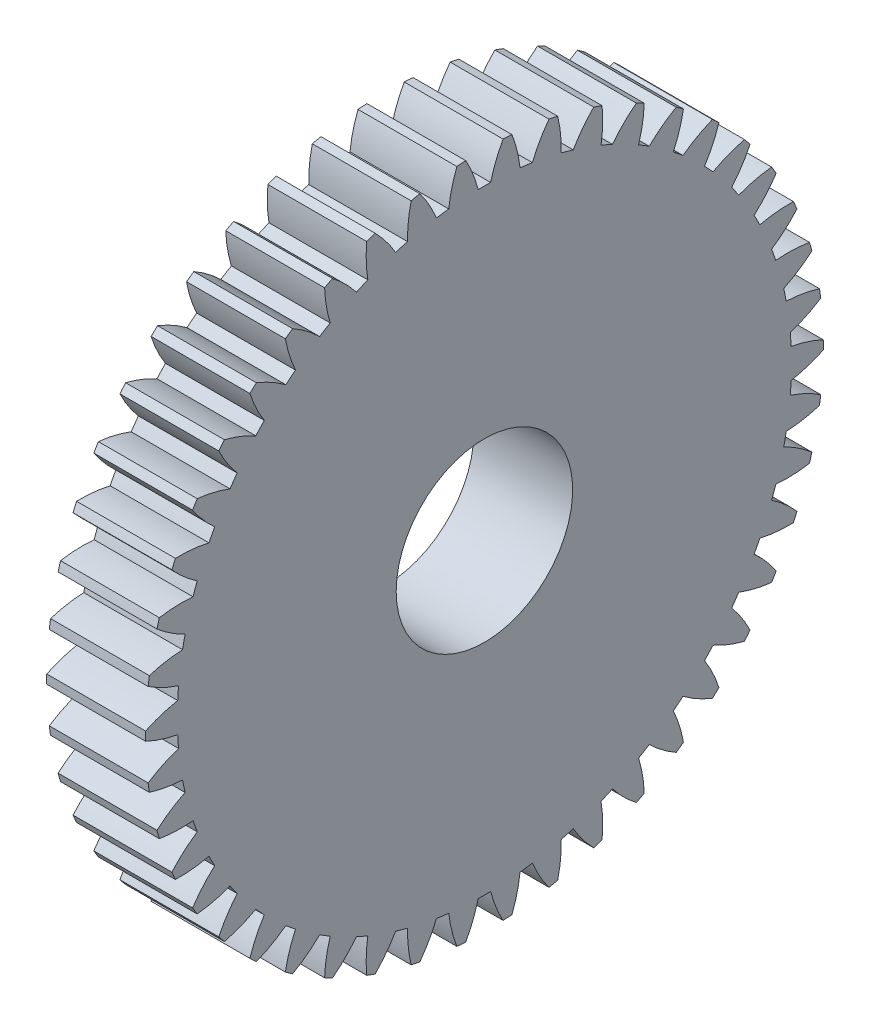
from build123d import *

# Parameters (mm, degrees)
BASPROSKE_W     = 2.8
BASPROSKE_H     = 9.6
TOOTHCUT_DEPTH  = 14.862178761
TEETHCUTS_COUNT = 46
TEETHCUTS_ANGLE = 352.173913043
BORSKE_R        = 2.5
BORE_DEPTH      = 50.0000508


with BuildPart() as part:
    # BasProSke → Base-Revolve (revolve)
    with BuildSketch(Plane(origin=(0, 0, 0), x_dir=(1, 0, 0), z_dir=(0, 1, 0)), mode=Mode.PRIVATE) as base_revolve_sk:
        with Locations((1.4, 4.8)):
            Rectangle(BASPROSKE_W, BASPROSKE_H)
    revolve(base_revolve_sk.sketch.rotate(Axis((-10, 0, 0), (1, 0, 0)), 180), axis=Axis((-10, 0, 0), (1, 0, 0)))

    # TooCutSke → ToothCut (cut, through all)
    with BuildSketch(Plane(origin=(0, 0, 0), x_dir=(0, 0, -1), z_dir=(1, 0, 0))):
        with BuildLine():
            ThreePointArc((0.176128274, 8.697216786), (0, 8.699), (-0.176128274, 8.697216786))
            ThreePointArc((-0.176128274, 8.697216786), (-0.329056987, 9.165962067), (-0.54327632, 9.610055983))
            ThreePointArc((-0.54327632, 9.610055983), (0, 9.6254), (0.54327632, 9.610055983))
            ThreePointArc((0.54327632, 9.610055983), (0.329056987, 9.165962067), (0.176128274, 8.697216786))
        make_face()
    toothcut = extrude(amount=TOOTHCUT_DEPTH, mode=Mode.SUBTRACT)

    # TeethCuts: ToothCut ×46 about axis
    teethcuts_axis = Axis((-10, 0, 0), (1, 0, 0))
    for i in range(1, TEETHCUTS_COUNT):
        add(toothcut.rotate(teethcuts_axis, i * TEETHCUTS_ANGLE / (TEETHCUTS_COUNT - 1)), mode=Mode.SUBTRACT)

    # BorSke → Bore (cut, symmetric)
    with BuildSketch(Plane(origin=(0, 0, 0), x_dir=(0, 0, -1), z_dir=(1, 0, 0))):
        with Locations(Location((0, 0, 0), (0, 0, 180))):
            Circle(BORSKE_R)
    extrude(amount=BORE_DEPTH, both=True, mode=Mode.SUBTRACT)


solid = part.part
